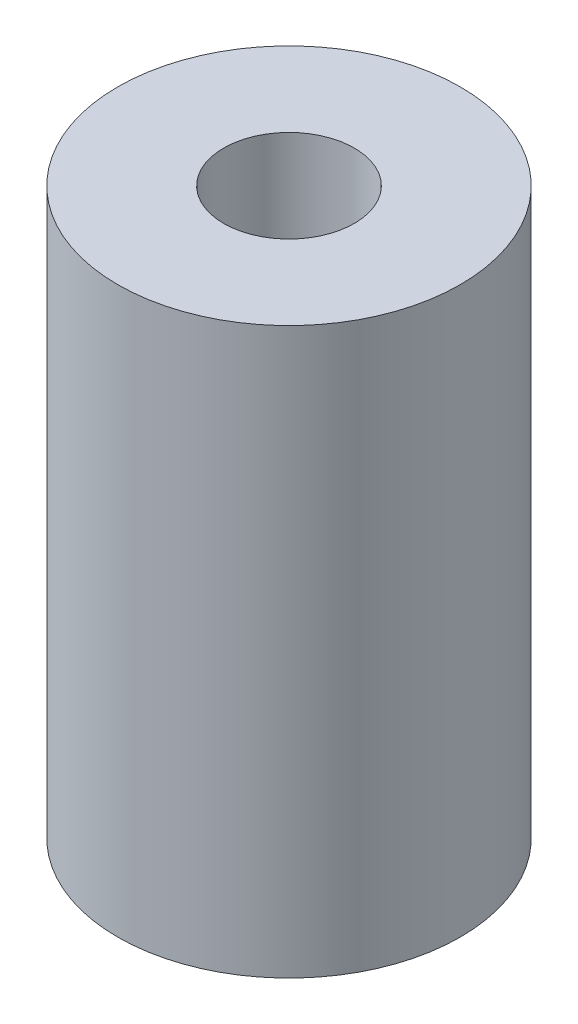
from build123d import *

# Parameters (mm, degrees)
SKETCH_1_R      = 4.85
SKETCH_1_R_2    = 1.85
EXTRUDE_1_DEPTH = 16


with BuildPart() as part:
    # 草图1 → 拉伸-薄壁1 (new body)
    with BuildSketch(Plane(origin=(0, 0, 0), x_dir=(1, 0, 0), z_dir=(0, 1, 0))):
        Circle(SKETCH_1_R)
        Circle(SKETCH_1_R_2, mode=Mode.SUBTRACT)
    extrude(amount=EXTRUDE_1_DEPTH)


solid = part.part
